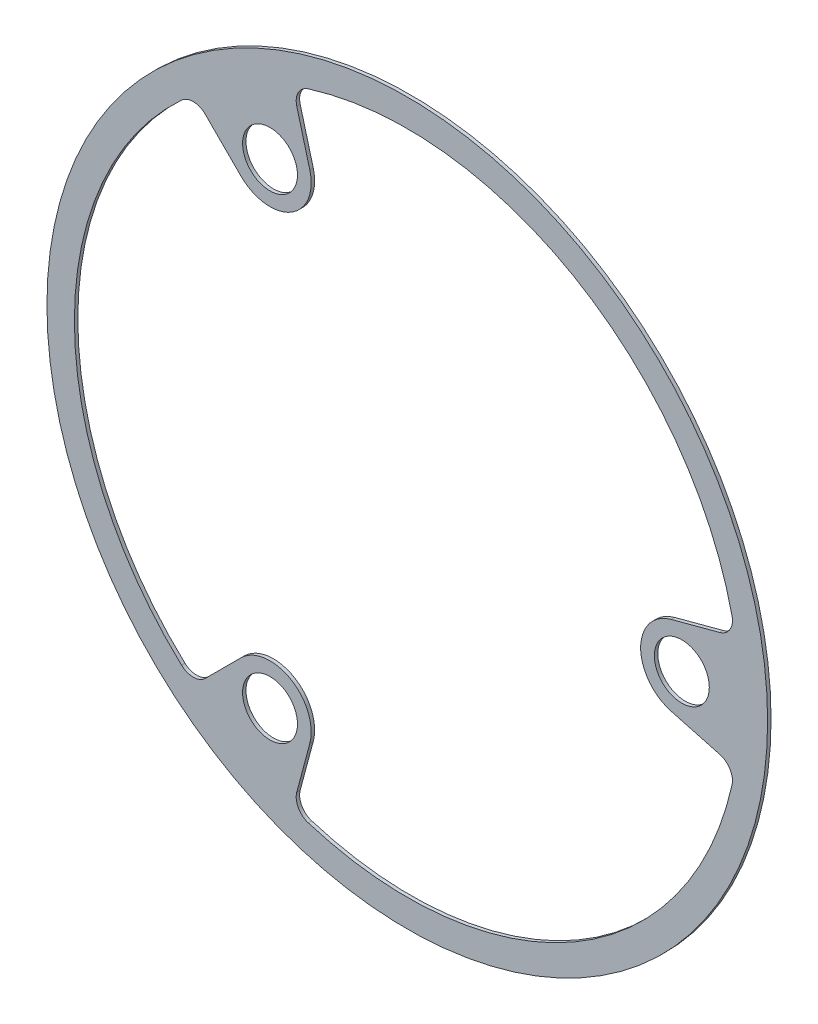
from build123d import *

# Parameters (mm, degrees)
ESQUISSE1_R        = 105
ESQUISSE1_R_2      = 8
BOSS_EXTRU_1_DEPTH = 1
CONG_1_R           = 5


with BuildPart() as part:
    # Esquisse1 → Boss.-Extru.1 (new body)
    with BuildSketch(Plane.XY):
        Circle(ESQUISSE1_R)
        with BuildLine():
            Line((95.569858419, 16.595245155), (76.894171459, 11.591109915))
            ThreePointArc((76.894171459, 11.591109915), (68, 0), (76.894171459, -11.591109915))
            Line((76.894171459, -11.591109915), (95.569858419, -16.595245155))
            ThreePointArc((95.569858419, -16.595245155), (48.5, -84.004464167), (-33.413025324, -91.063547804))
            Line((-33.413025324, -91.063547804), (-28.408890085, -72.387860844))
            ThreePointArc((-28.408890085, -72.387860844), (-34, -58.889727457), (-48.485281374, -60.796750929))
            Line((-48.485281374, -60.796750929), (-62.156833095, -74.46830265))
            ThreePointArc((-62.156833095, -74.46830265), (-97, 0), (-62.156833096, 74.46830265))
            Line((-62.156833096, 74.46830265), (-48.485281374, 60.796750929))
            ThreePointArc((-48.485281374, 60.796750929), (-34, 58.889727457), (-28.408890085, 72.387860844))
            Line((-28.408890085, 72.387860844), (-33.413025324, 91.063547804))
            ThreePointArc((-33.413025324, 91.063547804), (48.5, 84.004464167), (95.569858419, 16.595245155))
        make_face(mode=Mode.SUBTRACT)
        with Locations((80, 0)):
            Circle(ESQUISSE1_R_2, mode=Mode.SUBTRACT)
        with Locations((-40, 69.282032303)):
            Circle(ESQUISSE1_R_2, mode=Mode.SUBTRACT)
        with Locations((-40, -69.282032303)):
            Circle(ESQUISSE1_R_2, mode=Mode.SUBTRACT)
    extrude(amount=BOSS_EXTRU_1_DEPTH)

    # Congé1
    cong_1_edges = [part.edges().sort_by_distance(p)[0] for p in [
        (-62.156833096, 74.46830265, 0.5),
        (-62.156833095, -74.46830265, 0.5),
        (-33.413025324, -91.063547804, 0.5),
        (95.569858419, -16.595245155, 0.5),
        (95.569858419, 16.595245155, 0.5),
        (-33.413025324, 91.063547804, 0.5),
    ]]
    fillet(cong_1_edges, radius=CONG_1_R)


solid = part.part
